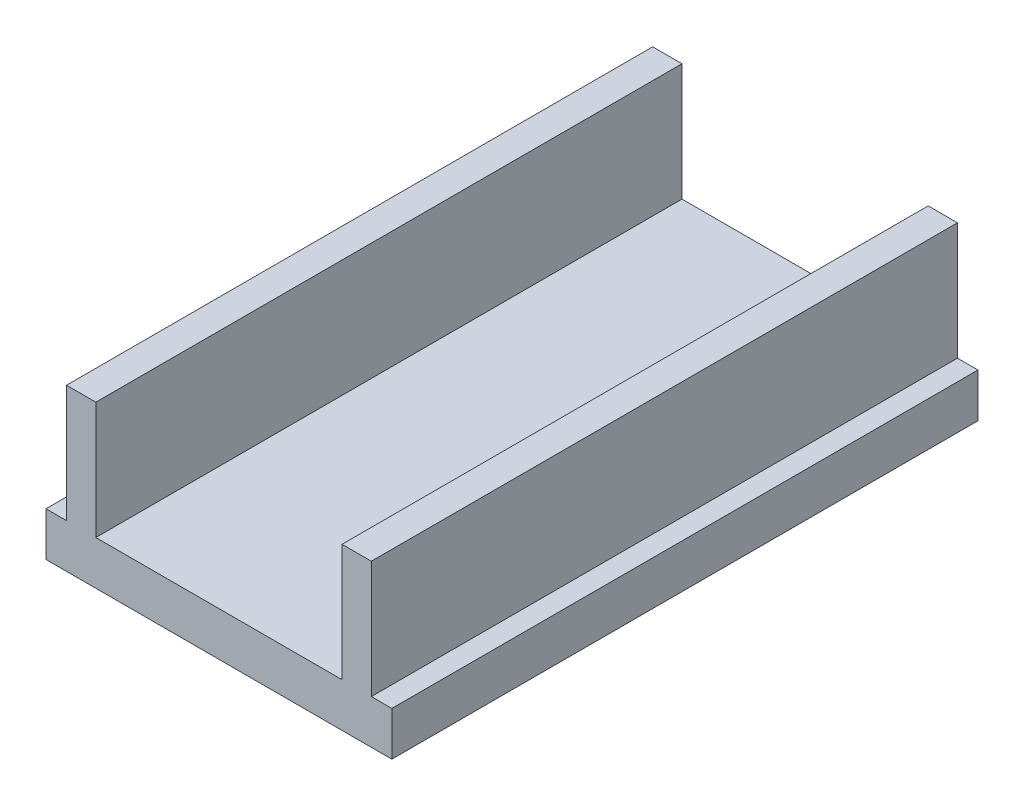
from build123d import *

# Parameters (mm, degrees)
SKETCH1_W           = 0.7
SKETCH1_H           = 20
SKETCH1_W_2         = 1
SKETCH1_W_3         = 8.4
BOSS_EXTRUDE1_DEPTH = 1.5
BOSS_EXTRUDE2_START = 1.5
SKETCH1_3_W         = 1
SKETCH1_3_H         = 20
BOSS_EXTRUDE2_DEPTH = 4


with BuildPart() as part:
    # Sketch1 → Boss-Extrude1 (new body)
    with BuildSketch(Plane(origin=(0, 0, 0), x_dir=(1, 0, 0), z_dir=(0, 1, 0))):
        with Locations((-5.931879195, 2.845637584)):
            Rectangle(SKETCH1_W, SKETCH1_H)
        with Locations((-5.081879195, 2.845637584)):
            Rectangle(SKETCH1_W_2, SKETCH1_H)
        with Locations((-0.381879195, 2.845637584)):
            Rectangle(SKETCH1_W_3, SKETCH1_H)
        with Locations((4.318120805, 2.845637584)):
            Rectangle(SKETCH1_W_2, SKETCH1_H)
        with Locations((5.168120805, 2.845637584)):
            Rectangle(SKETCH1_W, SKETCH1_H)
    extrude(amount=BOSS_EXTRUDE1_DEPTH)

    # Sketch1_3 → Boss-Extrude2 (add)
    with BuildSketch(Plane(origin=(0, 0, 0), x_dir=(1, 0, 0), z_dir=(0, 1, 0)).offset(BOSS_EXTRUDE2_START)):
        with Locations((-5.081879195, 2.845637584)):
            Rectangle(SKETCH1_3_W, SKETCH1_3_H)
        with Locations((4.318120805, 2.845637584)):
            Rectangle(SKETCH1_3_W, SKETCH1_3_H)
    extrude(amount=BOSS_EXTRUDE2_DEPTH)


solid = part.part
